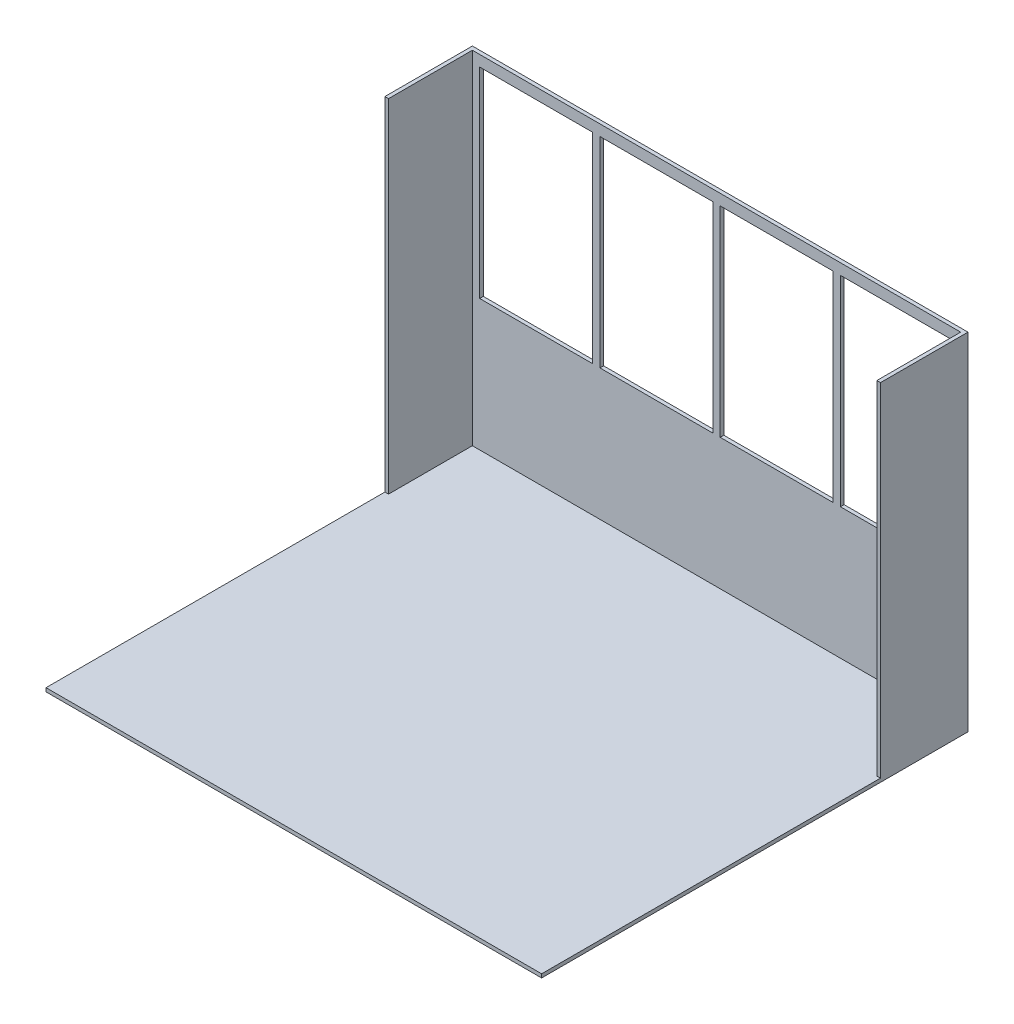
from build123d import *

# Parameters (mm, degrees)
SKETCH1_W           = 3454.4
SKETCH1_H           = 609.6
BOSS_EXTRUDE1_DEPTH = 2413
SHELL1_T            = -25.4
SKETCH2_W           = 3454.4
SKETCH2_H           = 25.4
BOSS_EXTRUDE2_DEPTH = 2362.2
SKETCH3_W           = 787.4
SKETCH3_H           = 1397
CUT_EXTRUDE1_DEPTH  = 25.4


with BuildPart() as part:
    # Sketch1 → Boss-Extrude1 (new body)
    with BuildSketch(Plane(origin=(0, 0, 0), x_dir=(1, 0, 0), z_dir=(0, 1, 0))):
        Rectangle(SKETCH1_W, SKETCH1_H)
    extrude(amount=BOSS_EXTRUDE1_DEPTH)

    # Shell1
    shell1_openings = [part.faces().sort_by_distance(p)[0] for p in [
        (0, 2413, 0),
        (0, 1206.5, 304.8),
    ]]
    offset(amount=SHELL1_T, openings=shell1_openings, kind=Kind.INTERSECTION)

    # Sketch2 → Boss-Extrude2 (add)
    with BuildSketch(Plane.XY.offset(304.8)):
        with Locations((0, 12.7)):
            Rectangle(SKETCH2_W, SKETCH2_H)
    extrude(amount=BOSS_EXTRUDE2_DEPTH)

    # Sketch3 → Cut-Extrude1 (cut)
    with BuildSketch(Plane.XY.offset(-279.4)):
        with Locations((-1257.3, 1638.3)):
            Rectangle(SKETCH3_W, SKETCH3_H)
        with Locations((-419.1, 1638.3)):
            Rectangle(SKETCH3_W, SKETCH3_H)
        with Locations((419.1, 1638.3)):
            Rectangle(SKETCH3_W, SKETCH3_H)
        with Locations((1257.3, 1638.3)):
            Rectangle(SKETCH3_W, SKETCH3_H)
    extrude(amount=-CUT_EXTRUDE1_DEPTH, mode=Mode.SUBTRACT)


solid = part.part
